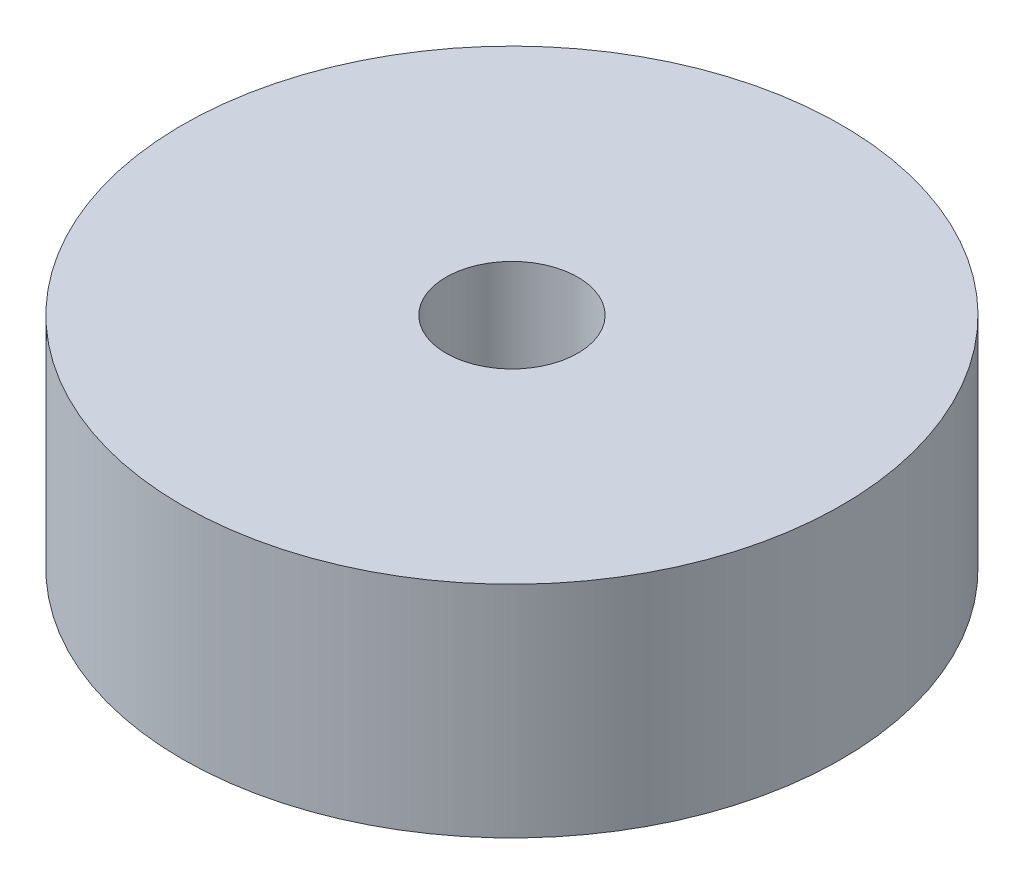
from build123d import *

# Parameters (mm, degrees)
SKETCH_1_R      = 15
SKETCH_1_R_2    = 3
EXTRUDE_1_DEPTH = 10


with BuildPart() as part:
    # 草图1 → 凸台-拉伸1 (new body)
    with BuildSketch(Plane(origin=(0, 0, 0), x_dir=(1, 0, 0), z_dir=(0, 1, 0))):
        Circle(SKETCH_1_R)
        Circle(SKETCH_1_R_2, mode=Mode.SUBTRACT)
    extrude(amount=EXTRUDE_1_DEPTH)


solid = part.part
